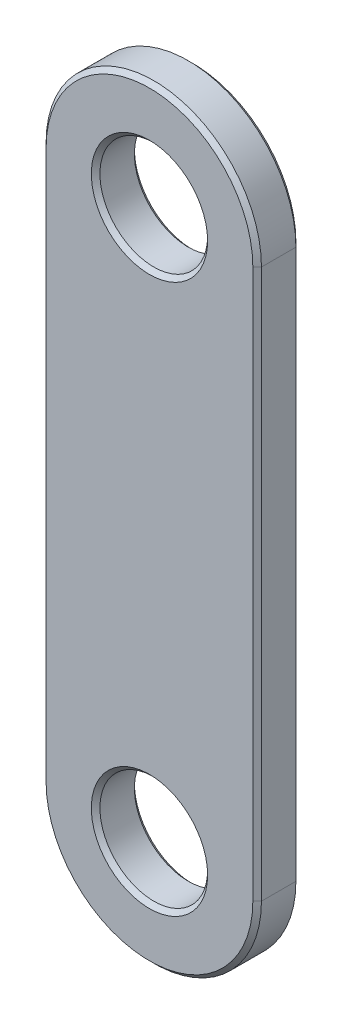
from build123d import *

# Parameters (mm, degrees)
SKETCH2_R           = 25
BOSS_EXTRUDE1_DEPTH = 20
CHAMFER1_SIZE       = 2


with BuildPart() as part:
    # Sketch2 → Boss-Extrude1 (new body)
    with BuildSketch(Plane.XY):
        with BuildLine():
            Line((50, 127.5), (50, -127.5))
            ThreePointArc((50, -127.5), (0, -177.5), (-50, -127.5))
            Line((-50, -127.5), (-50, 127.5))
            ThreePointArc((-50, 127.5), (0, 177.5), (50, 127.5))
        make_face()
        with Locations((0, 127.5)):
            Circle(SKETCH2_R, mode=Mode.SUBTRACT)
        with Locations((0, -127.5)):
            Circle(SKETCH2_R, mode=Mode.SUBTRACT)
    extrude(amount=BOSS_EXTRUDE1_DEPTH)

    # Chamfer1
    chamfer1_edges = [part.edges().sort_by_distance(p)[0] for p in [
        (-25, 127.5, 0),
        (-25, 127.5, 20),
        (0, -177.5, 20),
        (-25, -127.5, 0),
        (-25, -127.5, 20),
        (50, 0, 20),
        (0, 177.5, 20),
        (50, 0, 0),
        (0, -177.5, 0),
        (-50, 0, 0),
        (0, 177.5, 0),
        (-50, 0, 20),
    ]]
    chamfer(chamfer1_edges, length=CHAMFER1_SIZE)


solid = part.part
